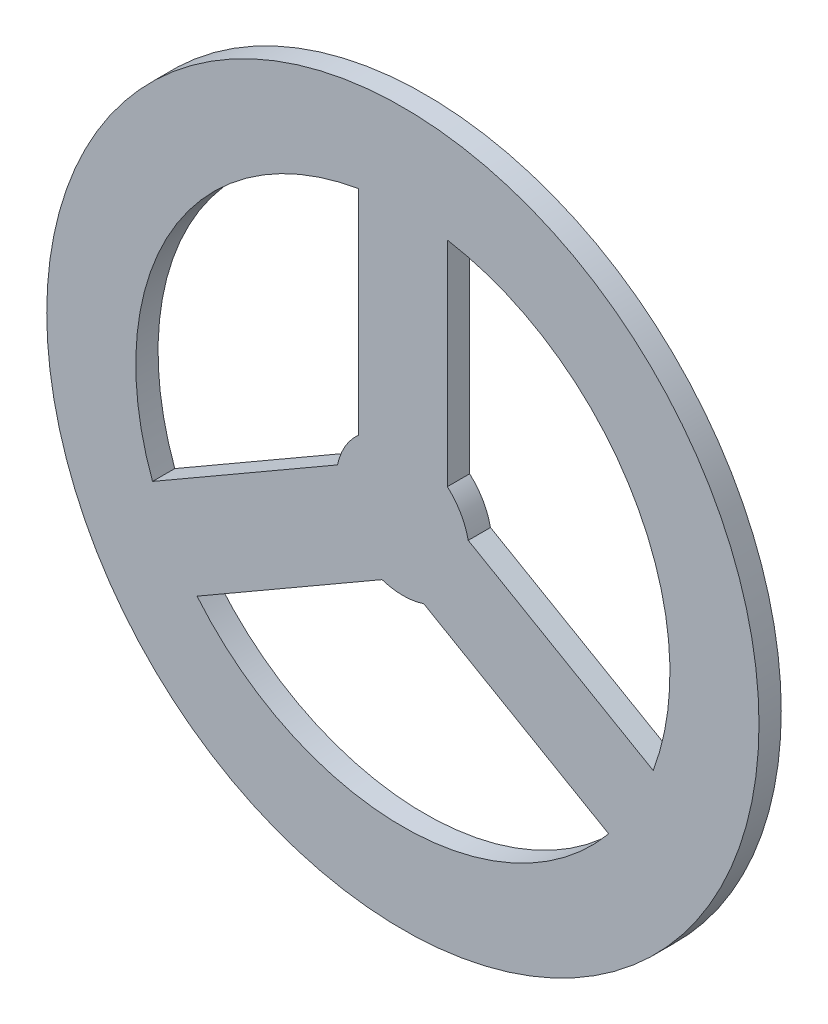
from build123d import *

# Parameters (mm, degrees)
SKETCH1_R           = 101.6
BOSS_EXTRUDE1_DEPTH = 6.35


with BuildPart() as part:
    # Sketch1 → Boss-Extrude1 (new body)
    with BuildSketch(Plane.XY):
        Circle(SKETCH1_R)
        with BuildLine():
            Line((-12.7, 14.199031657), (-12.7, 75.134213245))
            ThreePointArc((-12.7, 75.134213245), (-65.991135768, 38.1), (-71.418137364, -26.568583995))
            Line((-71.418137364, -26.568583995), (-18.646722124, 3.8990068))
            ThreePointArc((-18.646722124, 3.8990068), (-16.497783942, 9.525), (-12.7, 14.199031657))
        make_face(mode=Mode.SUBTRACT)
        with BuildLine():
            Line((12.7, 14.199031657), (12.7, 75.134213245))
            ThreePointArc((12.7, 75.134213245), (65.991135768, 38.1), (71.418137364, -26.568583995))
            Line((71.418137364, -26.568583995), (18.646722124, 3.8990068))
            ThreePointArc((18.646722124, 3.8990068), (16.497783942, 9.525), (12.7, 14.199031657))
        make_face(mode=Mode.SUBTRACT)
        with BuildLine():
            Line((5.946722124, -18.098038457), (58.718137364, -48.565629251))
            ThreePointArc((58.718137364, -48.565629251), (0, -76.2), (-58.718137364, -48.565629251))
            Line((-58.718137364, -48.565629251), (-5.946722124, -18.098038457))
            ThreePointArc((-5.946722124, -18.098038457), (0, -19.05), (5.946722124, -18.098038457))
        make_face(mode=Mode.SUBTRACT)
    extrude(amount=BOSS_EXTRUDE1_DEPTH)


solid = part.part
